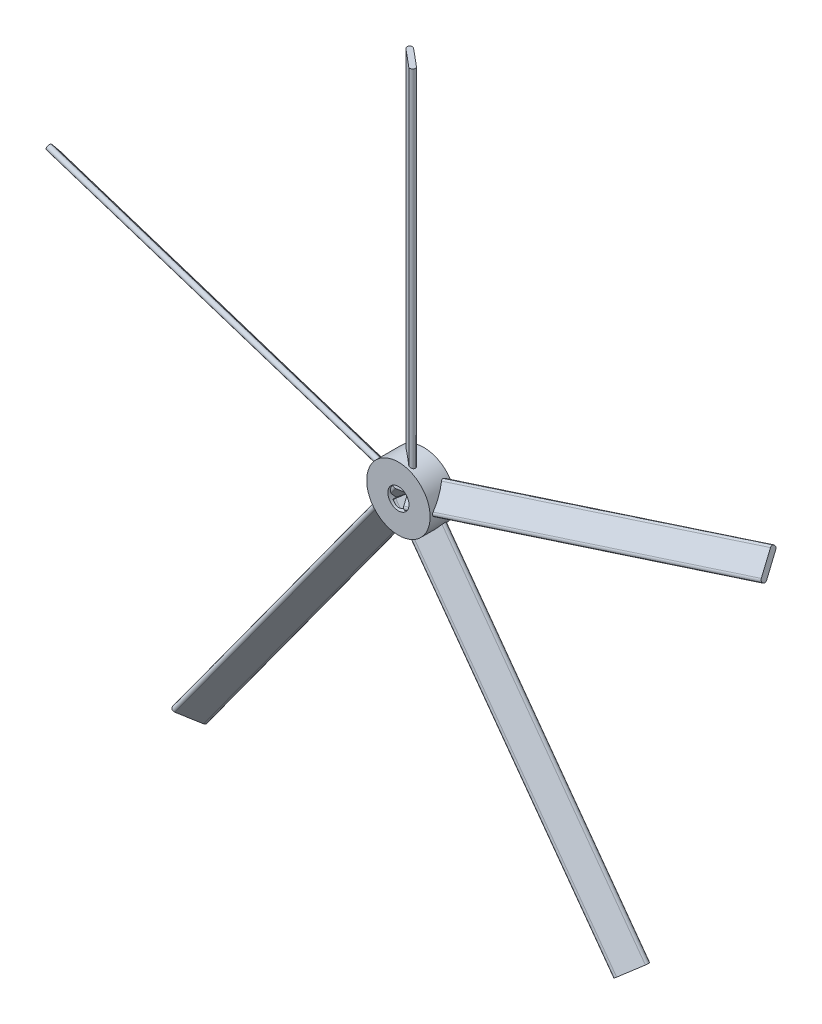
from build123d import *

# Parameters (mm, degrees)
SKETCH1_R           = 7.5
SKETCH1_R_2         = 2.5
BOSS_EXTRUDE1_DEPTH = 6
BOSS_EXTRUDE2_DEPTH = 88.9
CIRPATTERN1_COUNT   = 5


with BuildPart() as part:
    # Sketch1 → Boss-Extrude1 (new body)
    with BuildSketch(Plane.XY):
        Circle(SKETCH1_R)
        Circle(SKETCH1_R_2, mode=Mode.SUBTRACT)
    extrude(amount=BOSS_EXTRUDE1_DEPTH)

    # Sketch3 → Boss-Extrude2 (add)
    with BuildSketch(Plane(origin=(0, 0, 0), x_dir=(1, 0, 0), z_dir=(0, 1, 0))):
        with BuildLine():
            Line((-2.427610564, -1.81062126), (1.710616437, -5.267397014))
            ThreePointArc((1.710616437, -5.267397014), (2.617021972, -5.186071015), (2.535695974, -4.27966548))
            Line((2.535695974, -4.27966548), (-1.602531027, -0.822889726))
            ThreePointArc((-1.602531027, -0.822889726), (-2.508936562, -0.904215725), (-2.427610564, -1.81062126))
        make_face()
    boss_extrude2 = extrude(amount=BOSS_EXTRUDE2_DEPTH)

    # CirPattern1: Boss-Extrude2 ×5 about axis
    cirpattern1_axis = Axis((0, 0, 0), (0, 0, 1))
    for i in range(1, CIRPATTERN1_COUNT):
        add(boss_extrude2.rotate(cirpattern1_axis, i * 360 / CIRPATTERN1_COUNT))


solid = part.part
